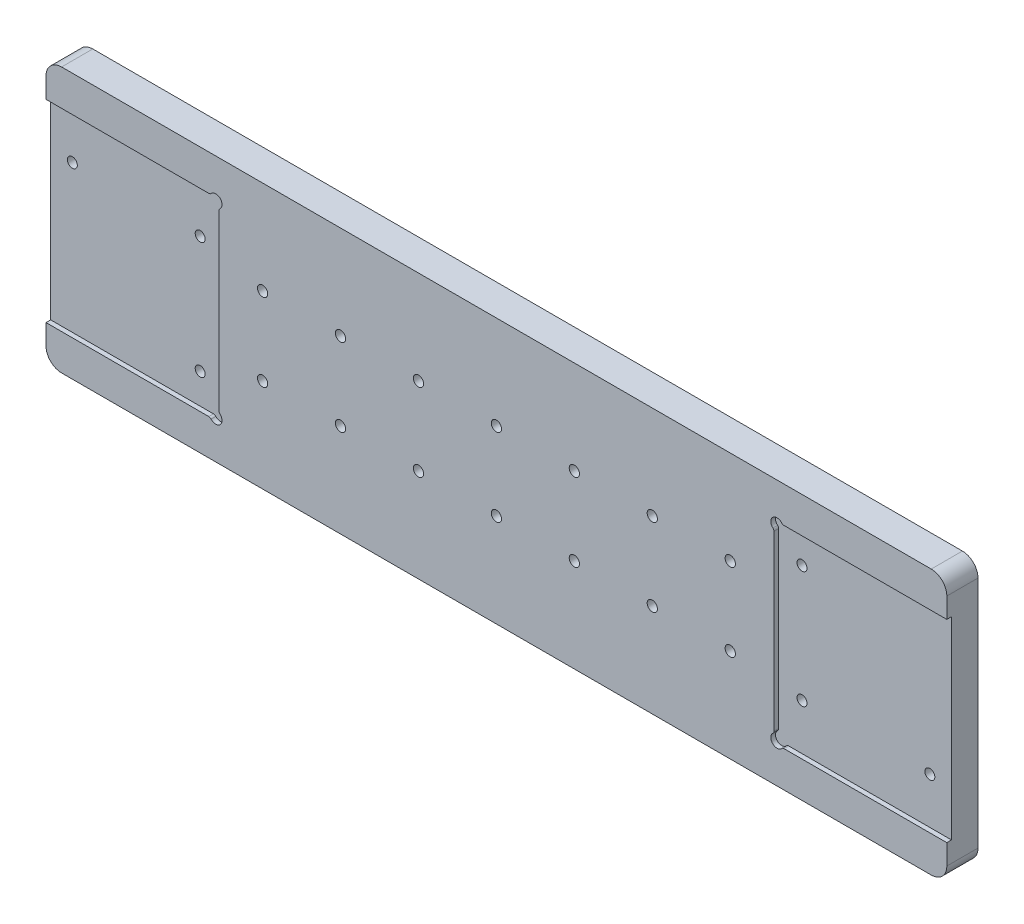
from build123d import *

# Parameters (mm, degrees)
ESTRUSIONE_ESTRUSIONE1_DEPTH                         = 3
ESTRUSIONE_ESTRUSIONE1_DEPTH_BACK                    = 17
TAGLIO_ESTRUSIONE1_DEPTH                             = 3
FORO_LAMATO_PER_VITE_M6_A_TESTA_CILINDRI_D           = 6.4
FORO_LAMATO_PER_VITE_M6_A_TESTA_CILINDRI_CBORE_D     = 11
FORO_LAMATO_PER_VITE_M6_A_TESTA_CILINDRI_CBORE_DEPTH = 6.4
RIPETIZIONECIRCOLARE1_COUNT                          = 2
FORO_PER_VITE_M6_1_D                                 = 6.6


with BuildPart() as part:
    # Schizzo2 → Estrusione-Estrusione1 (new body, two sides)
    with BuildSketch(Plane.XY) as estrusione_estrusione1_sk:
        with BuildLine():
            Line((-222.25, -85), (335.6, -85))
            ThreePointArc((335.6, -85), (342.671067812, -82.071067812), (345.6, -75))
            Line((345.6, -75), (345.6, 75))
            ThreePointArc((345.6, 75), (342.671067812, 82.071067812), (335.6, 85))
            Line((335.6, 85), (-222.25, 85))
            ThreePointArc((-222.25, 85), (-229.321067812, 82.071067812), (-232.25, 75))
            Line((-232.25, 75), (-232.25, -75))
            ThreePointArc((-232.25, -75), (-229.321067812, -82.071067812), (-222.25, -85))
        make_face()
    extrude(amount=ESTRUSIONE_ESTRUSIONE1_DEPTH)
    extrude(estrusione_estrusione1_sk.sketch, amount=-ESTRUSIONE_ESTRUSIONE1_DEPTH_BACK)

    # Schizzo3 → Taglio-Estrusione1 (cut)
    with BuildSketch(Plane.XY.offset(3)):
        with BuildLine():
            Line((-127.822135955, 62), (-232.25, 62))
            Line((-232.25, 62), (-232.25, -62))
            Line((-232.25, -62), (-127.822135955, -62))
            ThreePointArc((-127.822135955, -62), (-127.005639374, -62.174258142), (-126.33142397, -62.666666667))
            ThreePointArc((-126.33142397, -62.666666667), (-120.521572875, -62.828427125), (-120.683333333, -57.01857603))
            ThreePointArc((-120.683333333, -57.01857603), (-121.175741858, -56.344360626), (-121.35, -55.527864045))
            Line((-121.35, -55.527864045), (-121.35, 55.527864045))
            ThreePointArc((-121.35, 55.527864045), (-121.175741858, 56.344360626), (-120.683333333, 57.01857603))
            ThreePointArc((-120.683333333, 57.01857603), (-120.521572875, 62.828427125), (-126.33142397, 62.666666667))
            ThreePointArc((-126.33142397, 62.666666667), (-127.005639374, 62.174258142), (-127.822135955, 62))
        make_face()
    taglio_estrusione1 = extrude(amount=-TAGLIO_ESTRUSIONE1_DEPTH, mode=Mode.SUBTRACT)

    # Foro lamato per Vite M6 a testa cilindri (through all)
    with Locations(Plane(origin=(0, 0, -17), x_dir=(-1, 0, 0), z_dir=(0, 0, -1))):
        with Locations((136.35, -42.588457268), (136.35, 32.411542732), (218.35, 32.411542732)):
            foro_lamato_per_vite_m6_a_testa_cilindri = CounterBoreHole(FORO_LAMATO_PER_VITE_M6_A_TESTA_CILINDRI_D / 2, FORO_LAMATO_PER_VITE_M6_A_TESTA_CILINDRI_CBORE_D / 2, FORO_LAMATO_PER_VITE_M6_A_TESTA_CILINDRI_CBORE_DEPTH)

    # RipetizioneCircolare1: Taglio-Estrusione1, Foro lamato per Vite M6 a testa cilindri ×2 about axis
    ripetizionecircolare1_axis = Axis((56.675, 0, 0), (0, 0, 1))
    add([taglio_estrusione1.rotate(ripetizionecircolare1_axis, i * 360 / RIPETIZIONECIRCOLARE1_COUNT) for i in range(1, RIPETIZIONECIRCOLARE1_COUNT)], mode=Mode.SUBTRACT)
    add([foro_lamato_per_vite_m6_a_testa_cilindri.rotate(ripetizionecircolare1_axis, i * 360 / RIPETIZIONECIRCOLARE1_COUNT) for i in range(1, RIPETIZIONECIRCOLARE1_COUNT)], mode=Mode.SUBTRACT)

    # Foro per Vite M6-1 (through all)
    with Locations(Plane.XY.offset(3)):
        with Locations((-93.325, 25), (206.675, -25), (-93.325, -25), (206.675, 25), (56.675, 25), (56.675, -25), (-43.325, 25), (-43.325, -25), (6.675, -25), (6.675, 25), (106.675, -25), (106.675, 25), (156.675, 25), (156.675, -25)):
            Hole(FORO_PER_VITE_M6_1_D / 2)


solid = part.part
